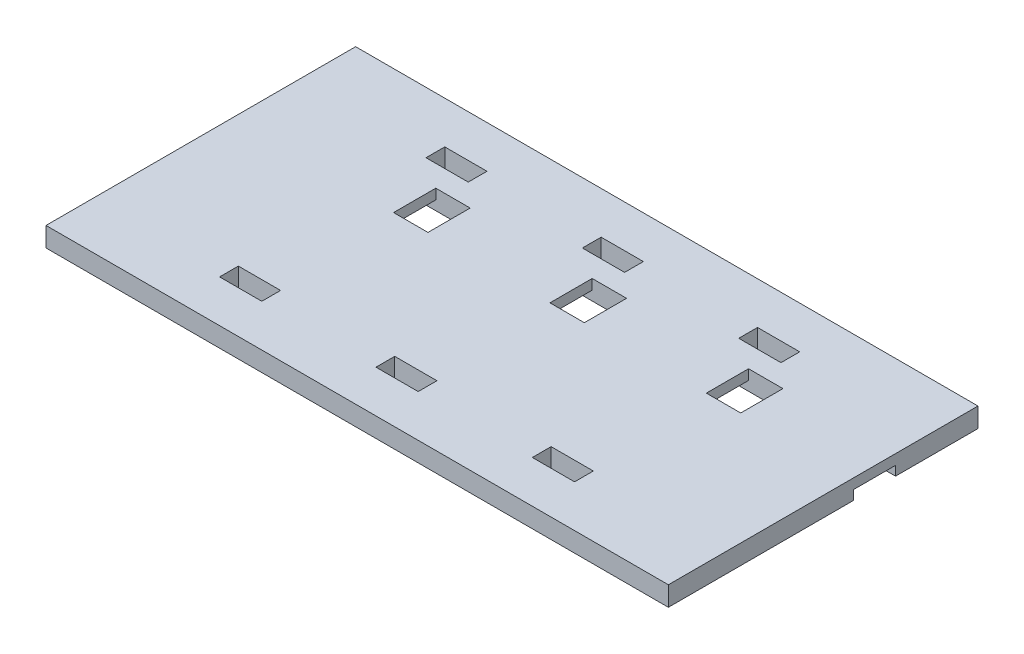
from build123d import *

# Parameters (mm, degrees)
SKETCH1_W                     = 101.092
SKETCH1_H                     = 50.292
BOSS_EXTRUDE1_DEPTH           = 3.175
SKETCH2_W                     = 5.588
SKETCH2_H                     = 6.858
WIRE_HOLE_DEPTH               = 4.175
SKETCH3_W                     = 6.858
SKETCH3_H                     = 3.048
CUT_EXTRUDE2_DEPTH            = 4.175
LPATTERN1_COUNT               = 2
LPATTERN1_PITCH               = 25.4
LPATTERN1_COPY_1_SKETCH_W     = 6.858
LPATTERN1_COPY_1_SKETCH_H     = 3.048
LPATTERN1_COPY_1_DEPTH        = 4.175
LPATTERN1_COL_COUNT           = 2
LPATTERN1_COL_PITCH           = 25.4
LPATTERN1_COL_COPY_1_SKETCH_W = 6.858
LPATTERN1_COL_COPY_1_SKETCH_H = 3.048
LPATTERN1_COL_COPY_1_DEPTH    = 4.175
SKETCH4_W                     = 101.092
SKETCH4_H                     = 6.858
CUT_EXTRUDE3_DEPTH            = 1.524


with BuildPart() as part:
    # Sketch1 → Boss-Extrude1 (new body)
    with BuildSketch(Plane(origin=(0, 0, 0), x_dir=(1, 0, 0), z_dir=(0, 1, 0))):
        Rectangle(SKETCH1_W, SKETCH1_H)
    extrude(amount=BOSS_EXTRUDE1_DEPTH)

    # Sketch2 → Wire Hole (cut, through all)
    with BuildSketch(Plane(origin=(0, 3.175, 0), x_dir=(1, 0, 0), z_dir=(0, 1, 0))):
        with Locations((4.064, 8.322545685)):
            Rectangle(SKETCH2_W, SKETCH2_H)
    wire_hole = extrude(amount=-WIRE_HOLE_DEPTH, mode=Mode.SUBTRACT)

    # Sketch3 → Cut-Extrude2 (cut, through all)
    with BuildSketch(Plane(origin=(0, 3.175, 0), x_dir=(1, 0, 0), z_dir=(0, 1, 0))):
        with Locations((-0.381, 16.764)):
            Rectangle(SKETCH3_W, SKETCH3_H)
    cut_extrude2 = extrude(amount=-CUT_EXTRUDE2_DEPTH, mode=Mode.SUBTRACT)

    # Mirror1: Cut-Extrude2 across plane
    add(cut_extrude2.mirror(Plane.XY), mode=Mode.SUBTRACT)

    # LPattern1: Wire Hole, Cut-Extrude2 ×2
    with Locations(*[(-i * LPATTERN1_PITCH, 0, 0) for i in range(1, LPATTERN1_COUNT)]):
        add(wire_hole, mode=Mode.SUBTRACT)
        add(cut_extrude2, mode=Mode.SUBTRACT)

    # LPattern1 copy 1 sketch → LPattern1 copy 1 (cut, through all)
    with BuildSketch(Plane(origin=(-25.4, 3.175, 0), x_dir=(1, 0, 0), z_dir=(0, 1, 0))):
        with Locations((-0.381, -16.764)):
            Rectangle(LPATTERN1_COPY_1_SKETCH_W, LPATTERN1_COPY_1_SKETCH_H)
    extrude(amount=-LPATTERN1_COPY_1_DEPTH, mode=Mode.SUBTRACT)

    # LPattern1 col: Wire Hole, Cut-Extrude2 ×2
    with Locations(*[(i * LPATTERN1_COL_PITCH, 0, 0) for i in range(1, LPATTERN1_COL_COUNT)]):
        add(wire_hole, mode=Mode.SUBTRACT)
        add(cut_extrude2, mode=Mode.SUBTRACT)

    # LPattern1 col copy 1 sketch → LPattern1 col copy 1 (cut, through all)
    with BuildSketch(Plane(origin=(25.4, 3.175, 0), x_dir=(1, 0, 0), z_dir=(0, 1, 0))):
        with Locations((-0.381, -16.764)):
            Rectangle(LPATTERN1_COL_COPY_1_SKETCH_W, LPATTERN1_COL_COPY_1_SKETCH_H)
    extrude(amount=-LPATTERN1_COL_COPY_1_DEPTH, mode=Mode.SUBTRACT)

    # Sketch4 → Cut-Extrude3 (cut)
    with BuildSketch(Plane(origin=(0, 0, 0), x_dir=(1, 0, 0), z_dir=(0, 1, 0))):
        with Locations((0, 8.322545685)):
            Rectangle(SKETCH4_W, SKETCH4_H)
    extrude(amount=CUT_EXTRUDE3_DEPTH, mode=Mode.SUBTRACT)


solid = part.part
